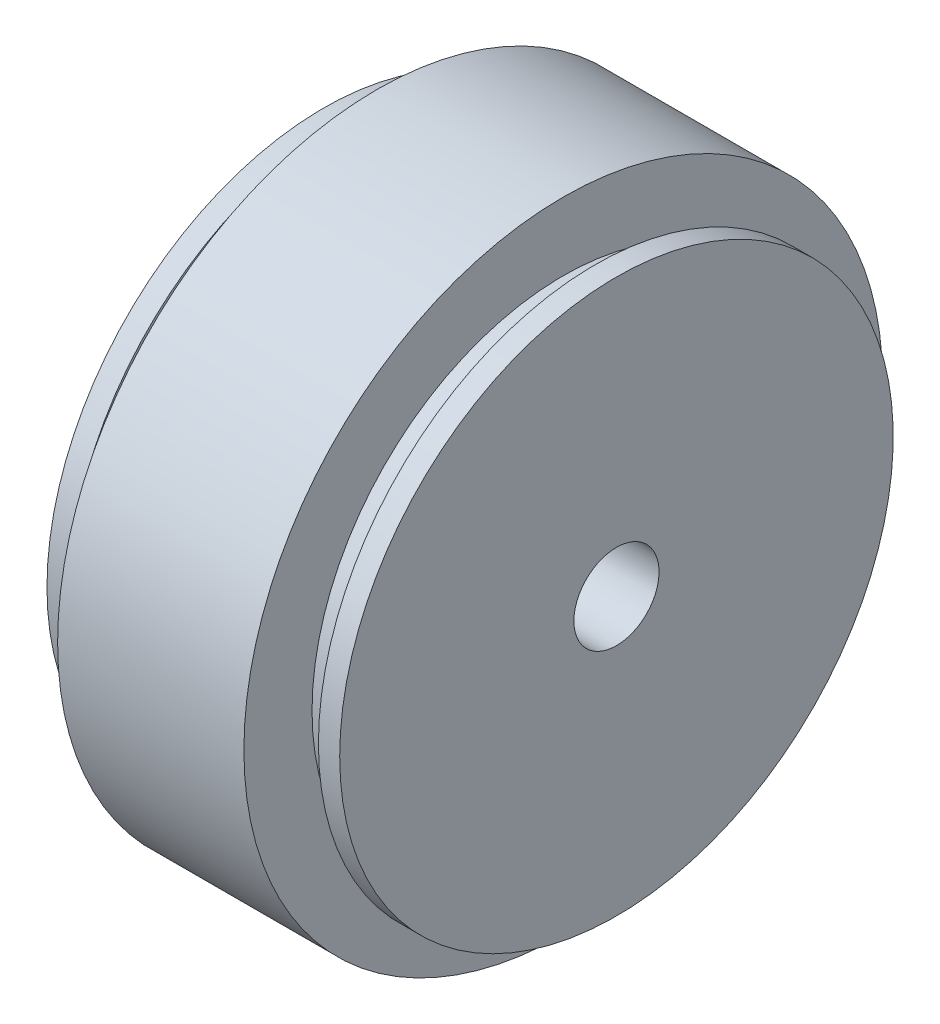
from build123d import *


with BuildPart() as part:
    # Esquisse1 → Révolution1 (revolve)
    with BuildSketch(Plane.XY):
        Polygon((-2.5, 19.6), (-2.5, 26), (-0.5, 26), (-0.5, 23.6), (2.5, 23.6), (2.5, 30), (20, 30), (20, 23.6), (23, 23.6), (23, 26), (25, 26), (25, 4), (10, 4), (10, 19.6), align=None)
    revolve(axis=Axis((10, 0, 0), (1, 0, 0)))


solid = part.part
